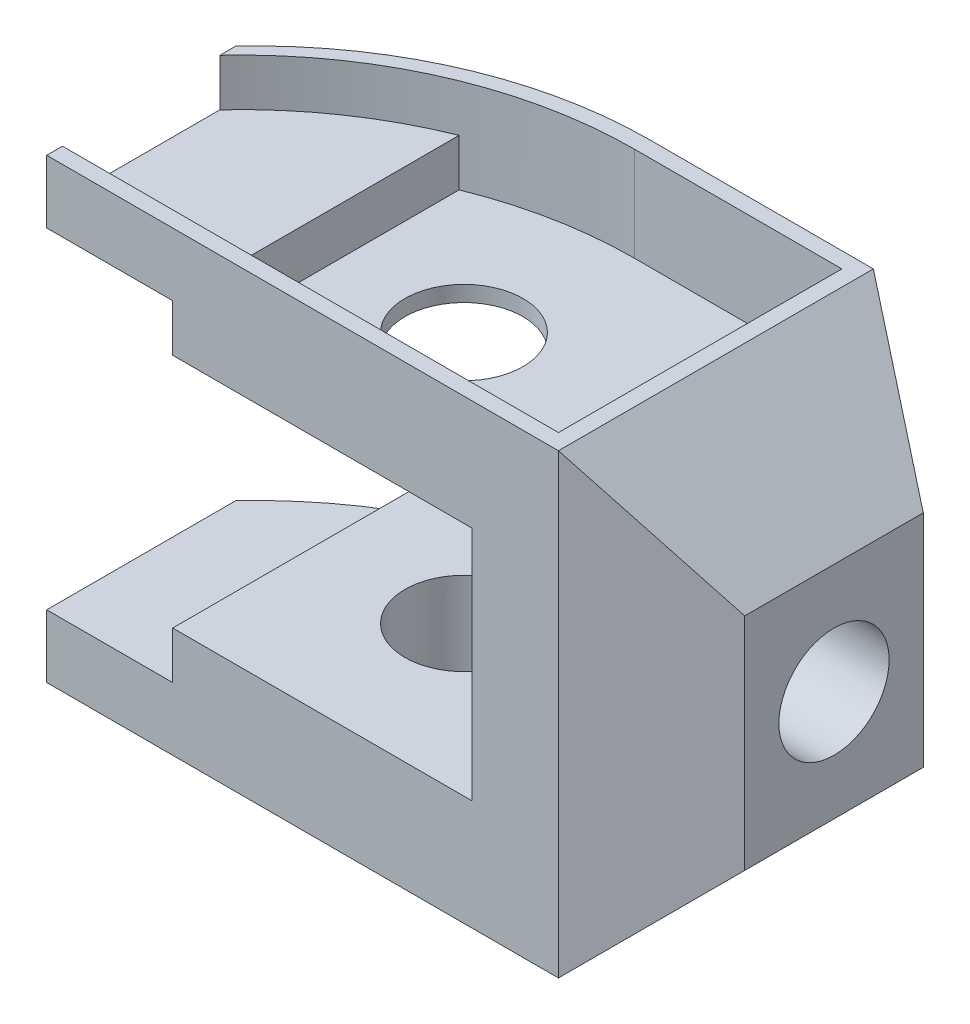
from build123d import *

# Parameters (mm, degrees)
SKETCH1_R           = 7.5
BOSS_EXTRUDE2_DEPTH = 58
CUT_EXTRUDE1_DEPTH  = 29
SKETCH6_R           = 7
CUT_EXTRUDE2_DEPTH  = 64
CUT_EXTRUDE3_DEPTH  = 64
CUT_EXTRUDE7_DEPTH  = 6
CUT_EXTRUDE8_DEPTH  = 6


with BuildPart() as part:
    # Sketch1 → Boss-Extrude2 (new body)
    with BuildSketch(Plane(origin=(0, 0, 0), x_dir=(1, 0, 0), z_dir=(0, 1, 0))):
        with BuildLine():
            Line((0, -19), (31, -19))
            Line((31, -19), (46, -10.339745962))
            Line((46, -10.339745962), (46, 12.339745962))
            Line((46, 12.339745962), (31, 21))
            Line((31, 21), (2.66060556, 21))
            ThreePointArc((2.66060556, 21), (-17.33939444, 16.82575695), (-34, 5))
            Line((-34, 5), (-34, -19))
            Line((-34, -19), (0, -19))
        make_face()
        Circle(SKETCH1_R, mode=Mode.SUBTRACT)
    extrude(amount=BOSS_EXTRUDE2_DEPTH)

    # Sketch4 → Cut-Extrude1 (cut, symmetric)
    with BuildSketch(Plane.XY):
        Polygon((31, 0), (46, 15), (46, 0), align=None)
        Polygon((31, 58), (46, 43), (46, 58), align=None)
    extrude(amount=CUT_EXTRUDE1_DEPTH, both=True, mode=Mode.SUBTRACT)

    # Sketch6 → Cut-Extrude2 (cut, symmetric)
    with BuildSketch(Plane(origin=(0, 0, 0), x_dir=(0, 0, -1), z_dir=(1, 0, 0))):
        with Locations((1, 29)):
            Circle(SKETCH6_R)
    extrude(amount=CUT_EXTRUDE2_DEPTH, both=True, mode=Mode.SUBTRACT)

    # Sketch7 → Cut-Extrude3 (cut, symmetric)
    with BuildSketch(Plane.XY.offset(19)):
        Polygon((-34, 50), (-18, 50), (-18, 44), (20, 44), (20, 14), (-18, 14), (-18, 8), (-34, 8), align=None)
    extrude(amount=CUT_EXTRUDE3_DEPTH, both=True, mode=Mode.SUBTRACT)

    # Sketch8 → Cut-Extrude7 (cut)
    with BuildSketch(Plane(origin=(0, 58, 0), x_dir=(1, 0, 0), z_dir=(0, 1, 0))):
        with BuildLine():
            Line((29, 19), (2.66060556, 19))
            ThreePointArc((2.66060556, 19), (-17.33939444, 14.82575695), (-34, 3))
            Line((-34, 3), (-34, -17))
            Line((-34, -17), (29, -17))
            Line((29, -17), (29, 19))
        make_face()
    extrude(amount=-CUT_EXTRUDE7_DEPTH, mode=Mode.SUBTRACT)

    # Sketch11 → Cut-Extrude8 (cut)
    with BuildSketch(Plane(origin=(0, 52, 0), x_dir=(1, 0, 0), z_dir=(0, 1, 0))):
        with BuildLine():
            Line((-16, -17), (29, -17))
            Line((29, -17), (29, 19))
            Line((29, 19), (2.66060556, 19))
            ThreePointArc((2.66060556, 19), (-6.842943589, 18.088517533), (-16, 15.387302143))
            Line((-16, 15.387302143), (-16, -17))
        make_face()
    extrude(amount=-CUT_EXTRUDE8_DEPTH, mode=Mode.SUBTRACT)


solid = part.part
